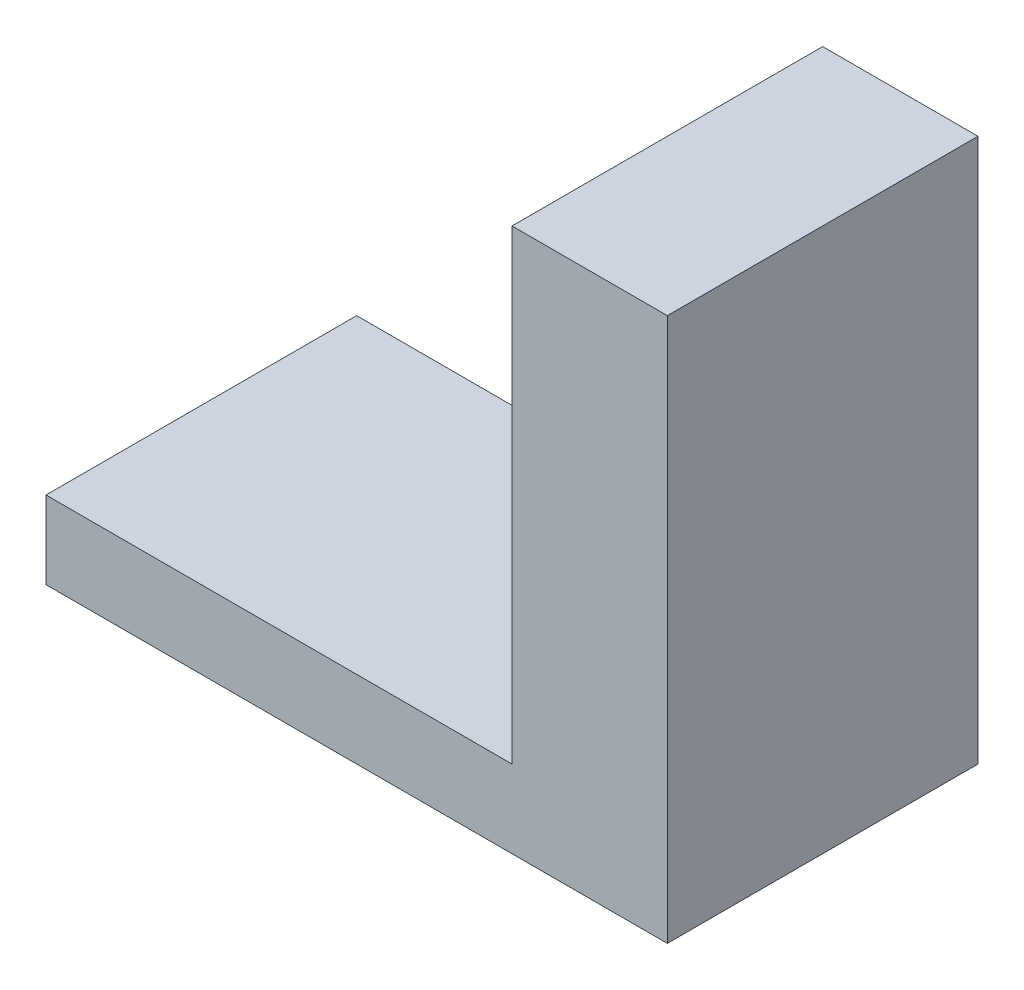
from build123d import *

# Parameters (mm, degrees)
SKETCH1_W           = 25.4
SKETCH1_H           = 12.7
BOSS_EXTRUDE1_DEPTH = 3.175
SKETCH2_W           = 6.35
SKETCH2_H           = 12.7
BOSS_EXTRUDE2_DEPTH = 19.05


with BuildPart() as part:
    # Sketch1 → Boss-Extrude1 (new body)
    with BuildSketch(Plane(origin=(0, 0, 0), x_dir=(1, 0, 0), z_dir=(0, 1, 0))):
        with Locations((-0.987777778, -0.176388889)):
            Rectangle(SKETCH1_W, SKETCH1_H)
    extrude(amount=BOSS_EXTRUDE1_DEPTH)

    # Sketch2 → Boss-Extrude2 (add)
    with BuildSketch(Plane(origin=(0, 3.175, 0), x_dir=(1, 0, 0), z_dir=(0, 1, 0))):
        with Locations((8.537222222, -0.176388889)):
            Rectangle(SKETCH2_W, SKETCH2_H)
    extrude(amount=BOSS_EXTRUDE2_DEPTH)


solid = part.part
